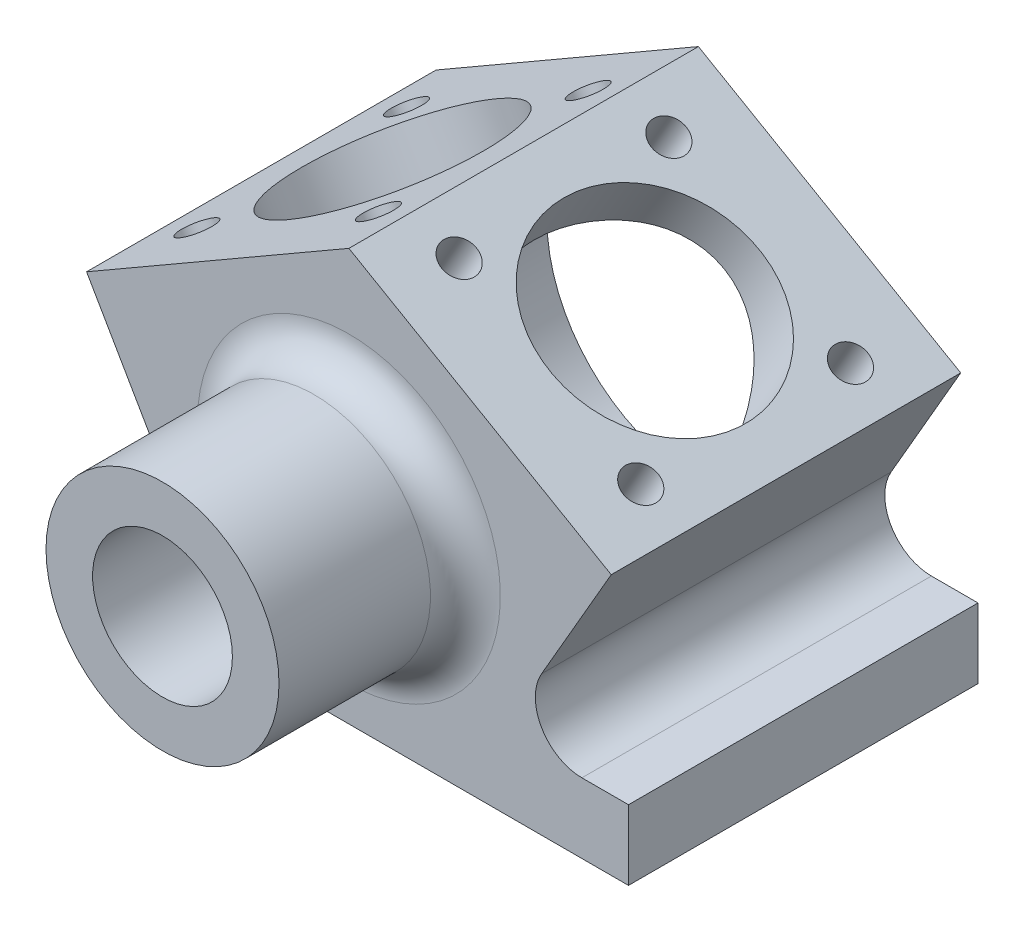
from build123d import *

# Parameters (mm, degrees)
BOSS_EXTRUDE1_DEPTH = 7.5
SKETCH2_R           = 5
BOSS_EXTRUDE2_DEPTH = 8
SKETCH3_R           = 6.5
CUT_EXTRUDE1_DEPTH  = 13
CUT_EXTRUDE2_REACH  = 25
SKETCH4_R           = 3
CUT_EXTRUDE3_START  = -6.308696
SKETCH5_R           = 4.5
CUT_EXTRUDE3_DEPTH  = 6.308696
SKETCH6_R           = 0.75
CUT_EXTRUDE4_DEPTH  = 2
FILLET1_R           = 1.5


with BuildPart() as part:
    # Sketch1 → Boss-Extrude1 (new body, symmetric)
    with BuildSketch(Plane.XY):
        with BuildLine():
            Line((-12, 0), (12, 0))
            Line((12, 0), (12, 3))
            Line((12, 3), (10, 3))
            ThreePointArc((10, 3), (8.267949192, 4), (8.267949192, 6))
            Line((8.267949192, 6), (11.258330249, 11.179491924))
            Line((11.258330249, 11.179491924), (0, 17.679491924))
            Line((0, 17.679491924), (-11.258330249, 11.179491924))
            Line((-11.258330249, 11.179491924), (-8.267949192, 6))
            ThreePointArc((-8.267949192, 6), (-8.267949192, 4), (-10, 3))
            Line((-10, 3), (-12, 3))
            Line((-12, 3), (-12, 0))
        make_face()
    extrude(amount=BOSS_EXTRUDE1_DEPTH, both=True)

    # Sketch2 → Boss-Extrude2 (add)
    with BuildSketch(Plane.XY.offset(7.5)):
        with Locations(Location((0, 8, 0), (0, 0, 180))):  # turned: the seam where the file's is
            Circle(SKETCH2_R)
    extrude(amount=BOSS_EXTRUDE2_DEPTH)

    # Sketch3 → Cut-Extrude1 (cut)
    with BuildSketch(Plane(origin=(0, 0, -7.5), x_dir=(-1, 0, 0), z_dir=(0, 0, -1))):
        with Locations((0, 8)):
            Circle(SKETCH3_R)
    extrude(amount=-CUT_EXTRUDE1_DEPTH, mode=Mode.SUBTRACT)

    # Sketch4 → Cut-Extrude2 (cut, up to next)
    with BuildSketch(Plane.XY.offset(15.5), mode=Mode.PRIVATE) as cut_extrude2_sk1:
        with Locations((0, 8)):
            Circle(SKETCH4_R)
    cut_extrude2_tool1 = extrude(cut_extrude2_sk1.sketch, amount=-CUT_EXTRUDE2_REACH, mode=Mode.PRIVATE) & part.part
    add(cut_extrude2_tool1.solids().sort_by_distance((0, 8, 15.5))[0], mode=Mode.SUBTRACT)

    # Sketch5 → Cut-Extrude3 (cut)
    with BuildSketch(Plane(origin=(7.655444566, 13.259618943, 0), x_dir=(0.866025404, -0.5, 0), z_dir=(0.5, 0.866025404, 0)).offset(CUT_EXTRUDE3_START)):
        with Locations(Location((-2.339745962, 0, 0), (0, 0, 180))):  # turned: the seam where the file's is
            Circle(SKETCH5_R)
    cut_extrude3 = extrude(amount=CUT_EXTRUDE3_DEPTH, mode=Mode.SUBTRACT)

    # Mirror1: Cut-Extrude3 across plane
    add(cut_extrude3.mirror(Plane(origin=(0, 0, 0), x_dir=(0, 0, 1), z_dir=(1, 0, 0))), mode=Mode.SUBTRACT)

    # Sketch6 → Cut-Extrude4 (cut)
    with BuildSketch(Plane(origin=(7.655444566, 13.259618943, 0), x_dir=(0.866025404, -0.5, 0), z_dir=(0.5, 0.866025404, 0))):
        with Locations(Location((-6.839745962, 4.5, 0), (0, 0, 180))):  # turned: the seam where the file's is
            Circle(SKETCH6_R)
        with Locations(Location((2.160254038, 4.5, 0), (0, 0, 180))):  # turned: the seam where the file's is
            Circle(SKETCH6_R)
        with Locations(Location((2.160254038, -4.5, 0), (0, 0, 180))):  # turned: the seam where the file's is
            Circle(SKETCH6_R)
        with Locations(Location((-6.839745962, -4.5, 0), (0, 0, 180))):  # turned: the seam where the file's is
            Circle(SKETCH6_R)
    cut_extrude4 = extrude(amount=-CUT_EXTRUDE4_DEPTH, mode=Mode.SUBTRACT)

    # Mirror2: Cut-Extrude4 across plane
    add(cut_extrude4.mirror(Plane(origin=(0, 0, 0), x_dir=(0, 0, 1), z_dir=(1, 0, 0))), mode=Mode.SUBTRACT)

    # Fillet1
    fillet1_edges = [part.edges().sort_by_distance(p)[0] for p in [
        (5, 8, 7.5),
    ]]
    fillet(fillet1_edges, radius=FILLET1_R)


solid = part.part
